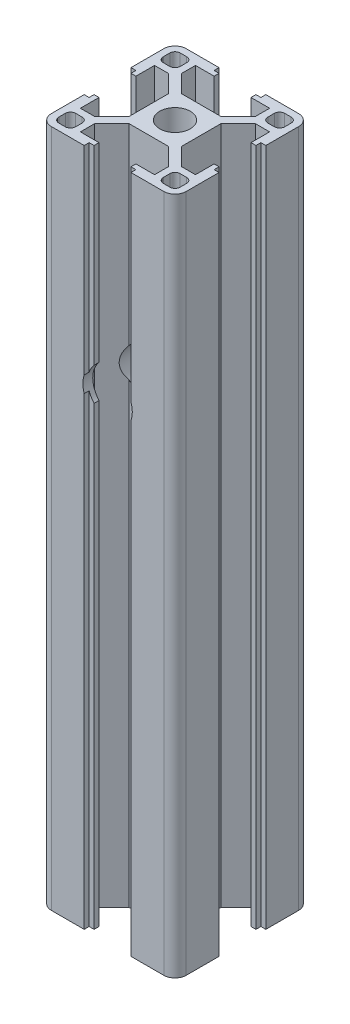
from build123d import *

# Parameters (mm, degrees)
SKETCH1_R               = 3.4
BOSS_EXTRUDE1_DEPTH     = 151
SKETCH2_R               = 3.125
SKETCH2_R_2             = 5.5
CUT_EXTRUDE2_DEPTH      = 107.454873068
CUT_EXTRUDE2_DEPTH_BACK = 107.454873068


with BuildPart() as part:
    # Sketch1 → Boss-Extrude1 (new body)
    with BuildSketch(Plane(origin=(0, 100, 0), x_dir=(1, 0, 0), z_dir=(0, 1, 0))):
        with BuildLine():
            Line((27.5, 0), (20.200000224, 0))
            Line((20.200000224, 0), (20.200000224, -1.1))
            Line((20.200000224, -1.1), (19.1, -1.1))
            Line((19.1, -1.1), (19.1, -2.2))
            Line((19.1, -2.2), (23.249999989, -2.2))
            Line((23.249999989, -2.2), (23.249999989, -5.335786427))
            Line((23.249999989, -5.335786427), (19.385786417, -9.2))
            Line((19.385786417, -9.2), (10.614213562, -9.2))
            Line((10.614213562, -9.2), (6.75, -5.335786438))
            Line((6.75, -5.335786438), (6.75, -2.2))
            Line((6.75, -2.2), (10.9, -2.2))
            Line((10.9, -2.2), (10.9, -1.1))
            Line((10.9, -1.1), (9.799999776, -1.1))
            Line((9.799999776, -1.1), (9.799999776, 0))
            Line((9.799999776, 0), (2.5, 0))
            ThreePointArc((2.5, 0), (0.732233047, -0.732233047), (0, -2.5))
            Line((0, -2.5), (0, -9.799999776))
            Line((0, -9.799999776), (1.1, -9.799999776))
            Line((1.1, -9.799999776), (1.1, -10.9))
            Line((1.1, -10.9), (2.199999979, -10.9))
            Line((2.199999979, -10.9), (2.199999979, -6.750000011))
            Line((2.199999979, -6.750000011), (5.335786427, -6.750000011))
            Line((5.335786427, -6.750000011), (9.199999989, -10.614213573))
            Line((9.199999989, -10.614213573), (9.199999989, -19.385786427))
            Line((9.199999989, -19.385786427), (5.335786417, -23.25))
            Line((5.335786417, -23.25), (2.199999979, -23.25))
            Line((2.199999979, -23.25), (2.199999979, -19.1))
            Line((2.199999979, -19.1), (1.1, -19.1))
            Line((1.1, -19.1), (1.1, -20.200000224))
            Line((1.1, -20.200000224), (0, -20.200000224))
            Line((0, -20.200000224), (0, -27.5))
            ThreePointArc((0, -27.5), (0.732233047, -29.267766953), (2.5, -30))
            Line((2.5, -30), (9.799999776, -30))
            Line((9.799999776, -30), (9.799999776, -28.9))
            Line((9.799999776, -28.9), (10.9, -28.9))
            Line((10.9, -28.9), (10.9, -27.8))
            Line((10.9, -27.8), (6.75, -27.8))
            Line((6.75, -27.8), (6.75, -24.664213562))
            Line((6.75, -24.664213562), (10.614213562, -20.8))
            Line((10.614213562, -20.8), (19.385786417, -20.8))
            Line((19.385786417, -20.8), (23.249999989, -24.664213573))
            Line((23.249999989, -24.664213573), (23.249999989, -27.8))
            Line((23.249999989, -27.8), (19.1, -27.8))
            Line((19.1, -27.8), (19.1, -28.9))
            Line((19.1, -28.9), (20.200000224, -28.9))
            Line((20.200000224, -28.9), (20.200000224, -30))
            Line((20.200000224, -30), (27.5, -30))
            ThreePointArc((27.5, -30), (29.267766953, -29.267766953), (30, -27.5))
            Line((30, -27.5), (30, -20.200000224))
            Line((30, -20.200000224), (28.9, -20.200000224))
            Line((28.9, -20.200000224), (28.9, -19.1))
            Line((28.9, -19.1), (27.799999979, -19.1))
            Line((27.799999979, -19.1), (27.799999979, -23.25))
            Line((27.799999979, -23.25), (24.664213562, -23.25))
            Line((24.664213562, -23.25), (20.799999989, -19.385786427))
            Line((20.799999989, -19.385786427), (20.799999989, -10.614213573))
            Line((20.799999989, -10.614213573), (24.664213552, -6.750000011))
            Line((24.664213552, -6.750000011), (27.799999979, -6.750000011))
            Line((27.799999979, -6.750000011), (27.799999979, -10.9))
            Line((27.799999979, -10.9), (28.9, -10.9))
            Line((28.9, -10.9), (28.9, -9.799999776))
            Line((28.9, -9.799999776), (30, -9.799999776))
            Line((30, -9.799999776), (30, -2.5))
            ThreePointArc((30, -2.5), (29.267766953, -0.732233047), (27.5, 0))
        make_face()
        with Locations(Location((15, -15, 0), (0, 0, 90))):
            Circle(SKETCH1_R, mode=Mode.SUBTRACT)
        with BuildLine():
            Line((28.5, -25.9), (28.5, -27.35))
            ThreePointArc((28.5, -27.35), (28.163172798, -28.163172798), (27.35, -28.5))
            Line((27.35, -28.5), (25.9, -28.5))
            ThreePointArc((25.9, -28.5), (25.086827202, -28.163172798), (24.75, -27.35))
            Line((24.75, -27.35), (24.75, -25.9))
            ThreePointArc((24.75, -25.9), (25.086827202, -25.086827202), (25.9, -24.75))
            Line((25.9, -24.75), (27.35, -24.75))
            ThreePointArc((27.35, -24.75), (28.163172798, -25.086827202), (28.5, -25.9))
        make_face(mode=Mode.SUBTRACT)
        with BuildLine():
            Line((1.5, -27.35), (1.5, -25.9))
            ThreePointArc((1.5, -25.9), (1.836827202, -25.086827202), (2.65, -24.75))
            Line((2.65, -24.75), (4.1, -24.75))
            ThreePointArc((4.1, -24.75), (4.913172798, -25.086827202), (5.25, -25.9))
            Line((5.25, -25.9), (5.25, -27.35))
            ThreePointArc((5.25, -27.35), (4.913172798, -28.163172798), (4.1, -28.5))
            Line((4.1, -28.5), (2.65, -28.5))
            ThreePointArc((2.65, -28.5), (1.836827202, -28.163172798), (1.5, -27.35))
        make_face(mode=Mode.SUBTRACT)
        with BuildLine():
            Line((2.65, -1.5), (4.1, -1.5))
            ThreePointArc((4.1, -1.5), (4.913172798, -1.836827202), (5.25, -2.65))
            Line((5.25, -2.65), (5.25, -4.1))
            ThreePointArc((5.25, -4.1), (4.913172798, -4.913172798), (4.1, -5.25))
            Line((4.1, -5.25), (2.65, -5.25))
            ThreePointArc((2.65, -5.25), (1.836827202, -4.913172798), (1.5, -4.1))
            Line((1.5, -4.1), (1.5, -2.65))
            ThreePointArc((1.5, -2.65), (1.836827202, -1.836827202), (2.65, -1.5))
        make_face(mode=Mode.SUBTRACT)
        with BuildLine():
            Line((28.5, -2.65), (28.5, -4.1))
            ThreePointArc((28.5, -4.1), (28.163172798, -4.913172798), (27.35, -5.25))
            Line((27.35, -5.25), (25.9, -5.25))
            ThreePointArc((25.9, -5.25), (25.086827202, -4.913172798), (24.75, -4.1))
            Line((24.75, -4.1), (24.75, -2.65))
            ThreePointArc((24.75, -2.65), (25.086827202, -1.836827202), (25.9, -1.5))
            Line((25.9, -1.5), (27.35, -1.5))
            ThreePointArc((27.35, -1.5), (28.163172798, -1.836827202), (28.5, -2.65))
        make_face(mode=Mode.SUBTRACT)
    extrude(amount=-BOSS_EXTRUDE1_DEPTH)

    # Sketch2 → Cut-Extrude2 (cut, two sides)
    with BuildSketch(Plane.XY.offset(20.8)) as cut_extrude2_sk:
        with Locations((14.999999989, 76.810128201)):
            Circle(SKETCH2_R)
        with Locations(Location((14.999999989, 53.997628201, 0), (0, 0, 37.115974958))):
            Circle(SKETCH2_R_2)
        with Locations((14.999999989, 31.185128201)):
            Circle(SKETCH2_R)
    extrude(amount=CUT_EXTRUDE2_DEPTH, mode=Mode.SUBTRACT)
    extrude(cut_extrude2_sk.sketch, amount=-CUT_EXTRUDE2_DEPTH_BACK, mode=Mode.SUBTRACT)


solid = part.part
